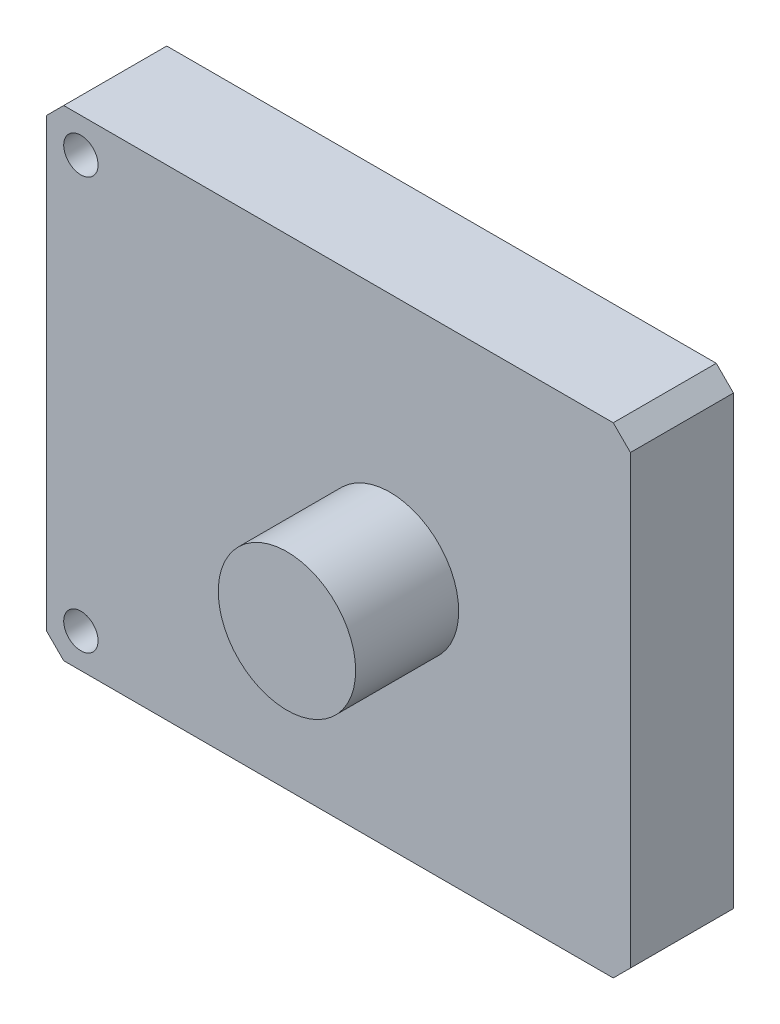
from build123d import *

# Parameters (mm, degrees)
CROQUIS1_W              = 170
CROQUIS1_H              = 140
SALIENTE_EXTRUIR1_DEPTH = 30
CHAFL_N1_SIZE           = 5
CROQUIS2_R              = 20
SALIENTE_EXTRUIR2_DEPTH = 30
CROQUIS2_3_R            = 5
CORTAR_EXTRUIR1_DEPTH   = 30


with BuildPart() as part:
    # Croquis1 → Saliente-Extruir1 (new body)
    with BuildSketch(Plane.XY):
        Rectangle(CROQUIS1_W, CROQUIS1_H)
    extrude(amount=SALIENTE_EXTRUIR1_DEPTH)

    # Chaflán1
    chafl_n1_edges = [part.edges().sort_by_distance(p)[0] for p in [
        (-85, 70, 15),
        (-85, -70, 15),
        (85, -70, 15),
        (85, 70, 15),
    ]]
    chamfer(chafl_n1_edges, length=CHAFL_N1_SIZE)

    # Croquis2 → Saliente-Extruir2 (add)
    with BuildSketch(Plane.XY.offset(30)):
        with Locations((15, 0)):
            Circle(CROQUIS2_R)
    extrude(amount=SALIENTE_EXTRUIR2_DEPTH)

    # Croquis2_3 → Cortar-Extruir1 (cut)
    with BuildSketch(Plane.XY.offset(30)):
        with Locations((-75, 60)):
            Circle(CROQUIS2_3_R)
        with Locations((-75, -60)):
            Circle(CROQUIS2_3_R)
    extrude(amount=-CORTAR_EXTRUIR1_DEPTH, mode=Mode.SUBTRACT)


solid = part.part
